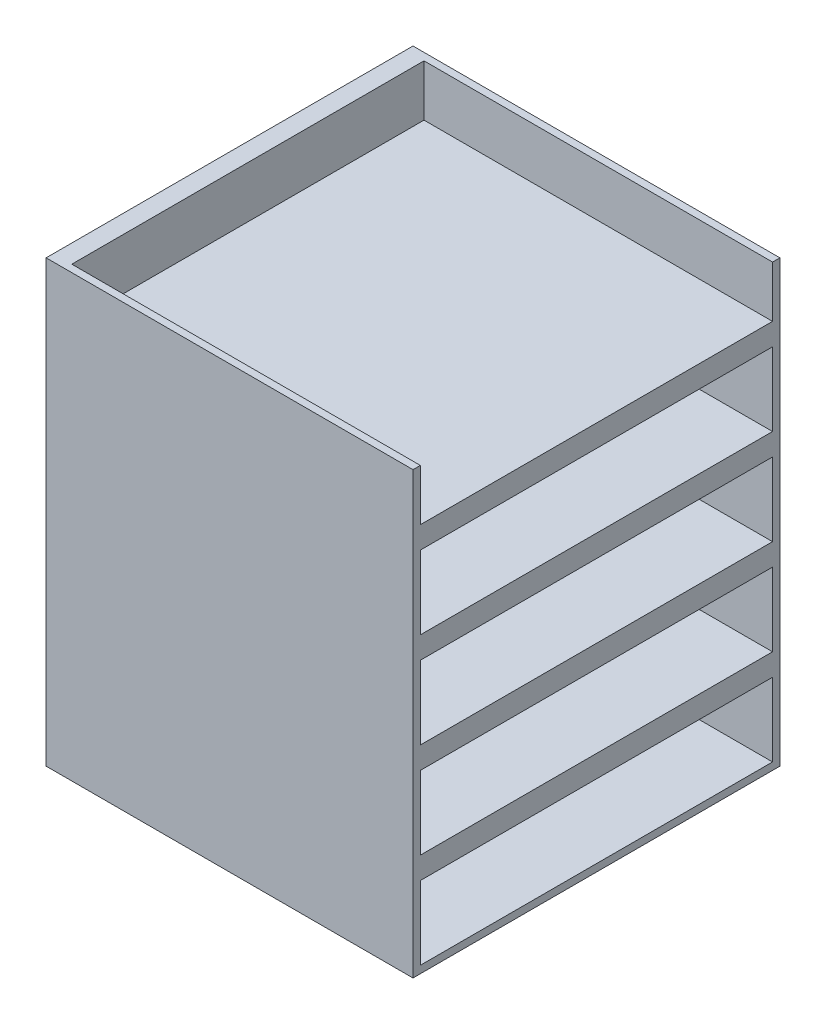
from build123d import *

# Parameters (mm, degrees)
SKETCH1_W           = 500
SKETCH1_H           = 500
BOSS_EXTRUDE1_DEPTH = 600
SKETCH3_W           = 480
SKETCH3_H           = 100
CUT_EXTRUDE2_DEPTH  = 475


with BuildPart() as part:
    # Sketch1 → Boss-Extrude1 (new body)
    with BuildSketch(Plane(origin=(0, 0, 0), x_dir=(1, 0, 0), z_dir=(0, 1, 0))):
        Rectangle(SKETCH1_W, SKETCH1_H)
    extrude(amount=BOSS_EXTRUDE1_DEPTH)

    # Sketch3 → Cut-Extrude2 (cut)
    with BuildSketch(Plane(origin=(250, 0, 0), x_dir=(0, 0, -1), z_dir=(1, 0, 0))):
        with Locations((0, 60)):
            Rectangle(SKETCH3_W, SKETCH3_H)
        with Locations((0, 190)):
            Rectangle(SKETCH3_W, SKETCH3_H)
        with Locations((0, 320)):
            Rectangle(SKETCH3_W, SKETCH3_H)
        with Locations((0, 450)):
            Rectangle(SKETCH3_W, SKETCH3_H)
        with Locations((0, 580)):
            Rectangle(SKETCH3_W, SKETCH3_H)
    extrude(amount=-CUT_EXTRUDE2_DEPTH, mode=Mode.SUBTRACT)


solid = part.part
